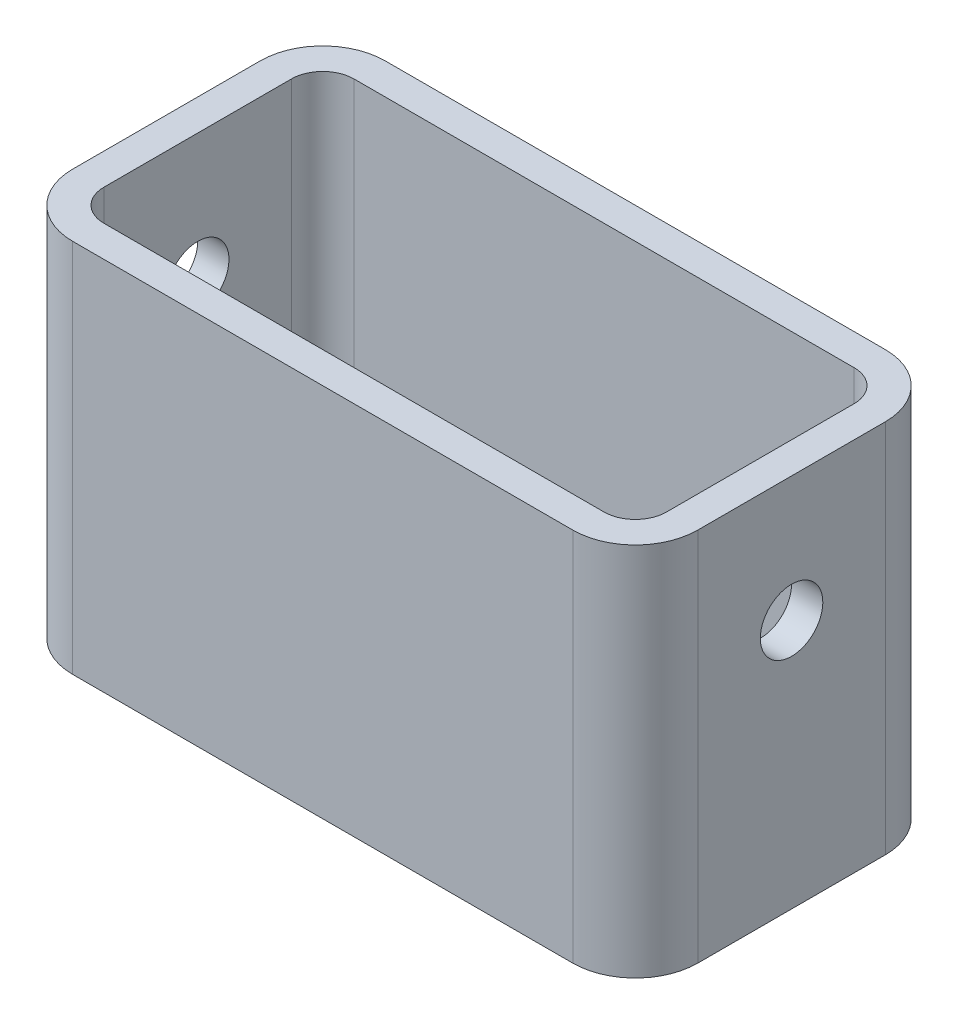
from build123d import *

# Parameters (mm, degrees)
SKETCH1_W           = 100
SKETCH1_H           = 60
BOSS_EXTRUDE1_DEPTH = 50
FILLET1_R           = 10
SHELL1_T            = -5
SKETCH2_R           = 5
CUT_EXTRUDE1_DEPTH  = 101


with BuildPart() as part:
    # Sketch1 → Boss-Extrude1 (new body)
    with BuildSketch(Plane.XY):
        with Locations((50, 30)):
            Rectangle(SKETCH1_W, SKETCH1_H)
    extrude(amount=BOSS_EXTRUDE1_DEPTH)

    # Fillet1
    fillet1_edges = [part.edges().sort_by_distance(p)[0] for p in [
        (100, 30, 50),
        (0, 30, 50),
        (100, 30, 0),
        (0, 30, 0),
    ]]
    fillet(fillet1_edges, radius=FILLET1_R)

    # Shell1
    shell1_openings = [part.faces().sort_by_distance(p)[0] for p in [
        (50, 60, 25),
    ]]
    offset(amount=SHELL1_T, openings=shell1_openings, kind=Kind.INTERSECTION)

    # Sketch2 → Cut-Extrude1 (cut, through all)
    with BuildSketch(Plane(origin=(100, 0, 0), x_dir=(0, 0, -1), z_dir=(1, 0, 0))):
        with Locations((-25, 40)):
            Circle(SKETCH2_R)
    extrude(amount=-CUT_EXTRUDE1_DEPTH, mode=Mode.SUBTRACT)


solid = part.part
